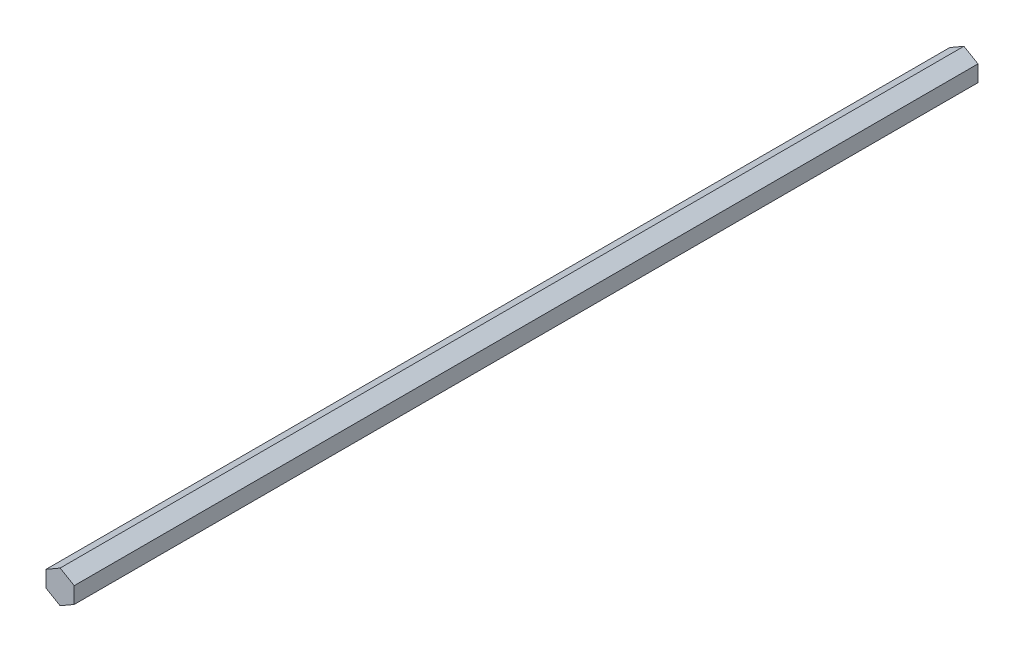
from build123d import *

# Parameters (mm, degrees)
BOSS_EXTRUDE1_DEPTH = 203.2


with BuildPart() as part:
    # Sketch1 → Boss-Extrude1 (new body, symmetric)
    with BuildSketch(Plane.XY):
        Polygon((0, -7.332348419), (6.35, -3.666174209), (6.35, 3.666174209), (0, 7.332348419), (-6.35, 3.666174209), (-6.35, -3.666174209), align=None)
    extrude(amount=BOSS_EXTRUDE1_DEPTH, both=True)


solid = part.part
